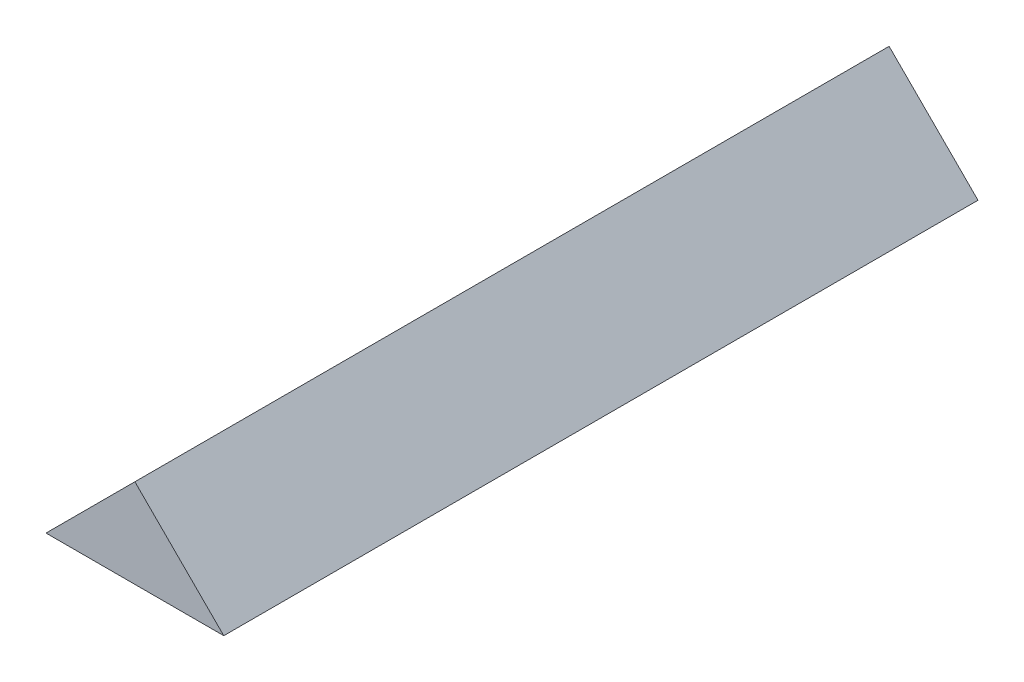
from build123d import *

# Parameters (mm, degrees)
BOSS_EXTRUDE1_DEPTH = 150


with BuildPart() as part:
    # Sketch1 → Boss-Extrude1 (new body)
    with BuildSketch(Plane.XY):
        Polygon((0, 0), (-35.355339059, 0), (-17.67766953, 17.67766953), align=None)
    extrude(amount=BOSS_EXTRUDE1_DEPTH)


solid = part.part
